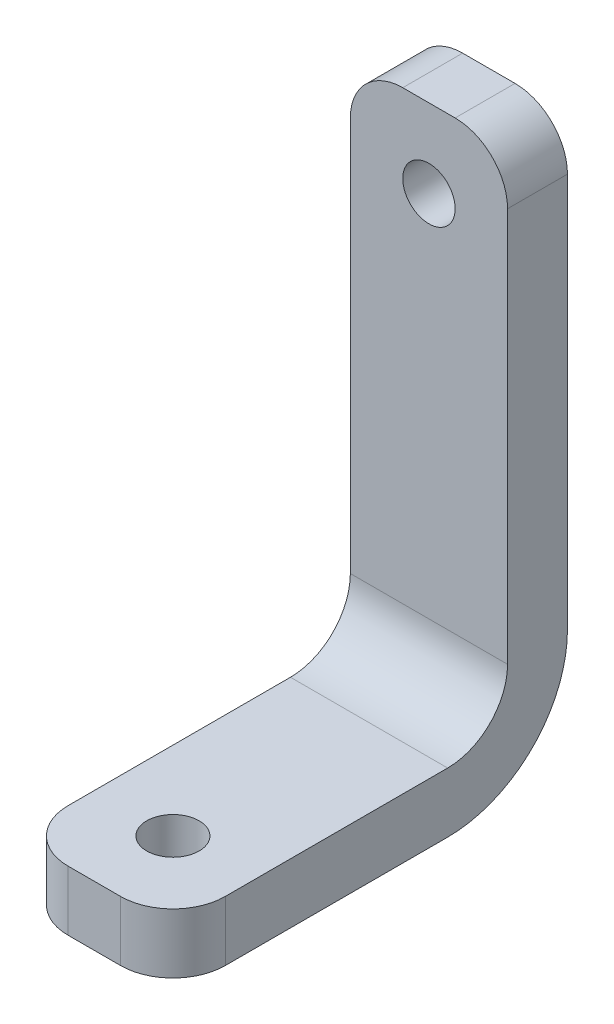
from build123d import *

# Parameters (mm, degrees)
ESQUISSE1_W             = 10.5
ESQUISSE1_H             = 37.85
ESQUISSE1_R             = 1.75
BOSS_EXTRU_1_DEPTH      = 4
ESQUISSE2_W             = 10.5
ESQUISSE2_H             = 4
BOSS_EXTRU_2_DEPTH      = 22.35
ENL_V_MAT_EXTRU_1_REACH = 39.85
ESQUISSE3_R             = 1.75
CONG_1_R                = 3.5
CONG_2_R                = 4
CONG_3_R                = 8


with BuildPart() as part:
    # Esquisse1 → Boss.-Extru.1 (new body)
    with BuildSketch(Plane.XY):
        Rectangle(ESQUISSE1_W, ESQUISSE1_H)
        with Locations((0, 13.675)):
            Circle(ESQUISSE1_R, mode=Mode.SUBTRACT)
    extrude(amount=BOSS_EXTRU_1_DEPTH)

    # Esquisse2 → Boss.-Extru.2 (add)
    with BuildSketch(Plane.XY.offset(4)):
        with Locations((0, -16.925)):
            Rectangle(ESQUISSE2_W, ESQUISSE2_H)
    extrude(amount=BOSS_EXTRU_2_DEPTH)

    # Esquisse3 → Enlèv. mat.-Extru.1 (cut, up to next)
    with BuildSketch(Plane.XZ.offset(18.925), mode=Mode.PRIVATE) as enl_v_mat_extru_1_sk1:
        with Locations((0, 21.1)):
            Circle(ESQUISSE3_R)
    enl_v_mat_extru_1_tool1 = extrude(enl_v_mat_extru_1_sk1.sketch, amount=-ENL_V_MAT_EXTRU_1_REACH, mode=Mode.PRIVATE) & part.part
    add(enl_v_mat_extru_1_tool1.solids().sort_by_distance((0, -18.925, 21.1))[0], mode=Mode.SUBTRACT)

    # Congé1
    cong_1_edges = [part.edges().sort_by_distance(p)[0] for p in [
        (-5.25, -16.925, 26.35),
        (5.25, -16.925, 26.35),
        (-5.25, 18.925, 2),
        (5.25, 18.925, 2),
    ]]
    fillet(cong_1_edges, radius=CONG_1_R)

    # Congé2
    cong_2_edges = [part.edges().sort_by_distance(p)[0] for p in [
        (0, -14.925, 4),
    ]]
    fillet(cong_2_edges, radius=CONG_2_R)

    # Congé3
    cong_3_edges = [part.edges().sort_by_distance(p)[0] for p in [
        (0, -18.925, 0),
    ]]
    fillet(cong_3_edges, radius=CONG_3_R)


solid = part.part
